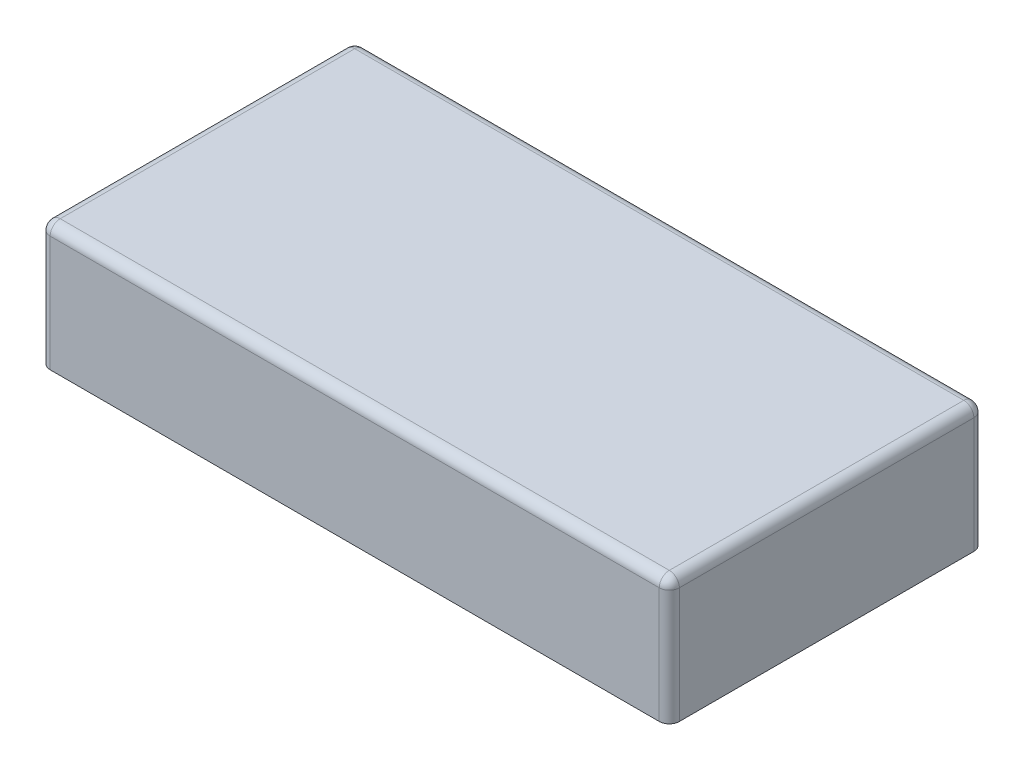
from build123d import *

# Parameters (mm, degrees)
SKETCH2_W           = 15.875
SKETCH2_H           = 7.9375
BOSS_EXTRUDE3_DEPTH = 3.175
SHELL1_T            = -1.524
FILLET1_R           = 0.254


with BuildPart() as part:
    # Sketch2 → Boss-Extrude3 (new body)
    with BuildSketch(Plane(origin=(0, 0, 0), x_dir=(1, 0, 0), z_dir=(0, 1, 0))):
        with Locations((-9.795613381, 4.754641089)):
            Rectangle(SKETCH2_W, SKETCH2_H)
    extrude(amount=BOSS_EXTRUDE3_DEPTH)

    # Shell1
    shell1_openings = [part.faces().sort_by_distance(p)[0] for p in [
        (-9.795613381, 0, -4.754641089),
    ]]
    offset(amount=SHELL1_T, openings=shell1_openings, kind=Kind.INTERSECTION)

    # Fillet1
    fillet1_edges = [part.edges().sort_by_distance(p)[0] for p in [
        (-1.858113381, 3.175, -4.754641089),
        (-9.795613381, 3.175, -8.723391089),
        (-17.733113381, 3.175, -4.754641089),
        (-17.733113381, 1.5875, -8.723391089),
        (-1.858113381, 1.5875, -8.723391089),
        (-1.858113381, 1.5875, -0.785891089),
        (-17.733113381, 1.5875, -0.785891089),
        (-9.795613381, 3.175, -0.785891089),
    ]]
    fillet(fillet1_edges, radius=FILLET1_R)


solid = part.part
